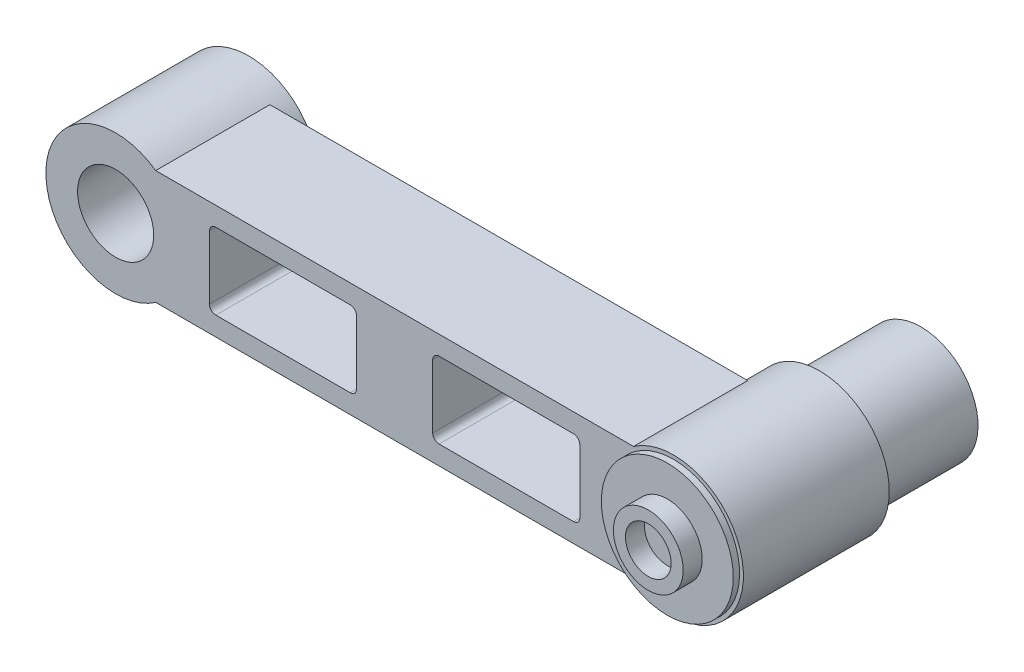
from build123d import *

# Parameters (mm, degrees)
BOSS_EXTRUDE5_DEPTH   = 90
SKETCH11_3_R          = 55
BOSS_EXTRUDE6_DEPTH   = 115
SKETCH11_4_R          = 55
BOSS_EXTRUDE7_DEPTH   = 105
BOSS_EXTRUDE8_DEPTH   = 15
SKETCH17_R            = 45
BOSS_EXTRUDE9_DEPTH   = 80
SKETCH18_R            = 52
BOSS_EXTRUDE10_DEPTH  = 5
SKETCH19_R            = 27.5
SKETCH19_R_2          = 18
BOSS_EXTRUDE12_DEPTH  = 15
BODY_MOVE_COPY2_ANGLE = 180
SKETCH28_R            = 52
CUT_EXTRUDE2_DEPTH    = 60
CUT_EXTRUDE3_DEPTH    = 80
SKETCH31_R            = 30
CUT_EXTRUDE6_DEPTH    = 196
BODY_MOVE_COPY3_ANGLE = 180
BODY_MOVE_COPY4_ANGLE = 90
BODY_MOVE_COPY6_ANGLE = 180
BODY_MOVE_COPY8_ANGLE = 90
BODY_MOVE_COPY9_ANGLE = 90
SKETCH36_R            = 24.5
CUT_EXTRUDE7_DEPTH    = 60


with BuildPart() as part:
    # Sketch11 → Boss-Extrude5 (new body)
    with BuildSketch(Plane.XY):
        with BuildLine():
            Line((-45, 408.377223398), (-45, 31.622776602))
            ThreePointArc((-45, 31.622776602), (0, -55), (45, 31.622776602))
            Line((45, 31.622776602), (45, 408.377223398))
            ThreePointArc((45, 408.377223398), (0, 495), (-45, 408.377223398))
        make_face()
    extrude(amount=BOSS_EXTRUDE5_DEPTH)

    # Sketch11_3 → Boss-Extrude6 (add)
    with BuildSketch(Plane.XY):
        with Locations((0, 440)):
            Circle(SKETCH11_3_R)
    extrude(amount=BOSS_EXTRUDE6_DEPTH)

    # Sketch11_4 → Boss-Extrude7 (add)
    with BuildSketch(Plane.XY):
        Circle(SKETCH11_4_R)
    extrude(amount=BOSS_EXTRUDE7_DEPTH)

    # Sketch13 → Boss-Extrude8 (add)
    with BuildSketch(Plane.XY.offset(90)):
        with BuildLine():
            Line((7.638888889, 82), (7.638888889, 54.46693838))
            Line((7.638888889, 54.46693838), (-7.638888889, 54.46693838))
            Line((-7.638888889, 54.46693838), (-7.638888889, 82))
            ThreePointArc((-7.638888889, 82), (0, 89.638888889), (7.638888889, 82))
        make_face()
    extrude(amount=BOSS_EXTRUDE8_DEPTH)

    # Sketch17 → Boss-Extrude9 (add)
    with BuildSketch(Plane.XY.offset(115)):
        with Locations((0, 440)):
            Circle(SKETCH17_R)
    extrude(amount=BOSS_EXTRUDE9_DEPTH)

    # Sketch18 → Boss-Extrude10 (add)
    with BuildSketch(Plane(origin=(0, 0, 0), x_dir=(-1, 0, 0), z_dir=(0, 0, -1))):
        with Locations((0, 440)):
            Circle(SKETCH18_R)
    extrude(amount=BOSS_EXTRUDE10_DEPTH)

    # Sketch19 → Boss-Extrude12 (add)
    with BuildSketch(Plane(origin=(0, 0, -5), x_dir=(-1, 0, 0), z_dir=(0, 0, -1))):
        with Locations((0, 440)):
            Circle(SKETCH19_R)
        with Locations((0, 440)):
            Circle(SKETCH19_R_2, mode=Mode.SUBTRACT)
    extrude(amount=BOSS_EXTRUDE12_DEPTH)


with BuildPart() as part_1:
    # Body-Move_Copy2: moved
    add(part.part.rotate(Axis((0, 0, 0), (0, 1, 0)), BODY_MOVE_COPY2_ANGLE))

    # Sketch28 → Cut-Extrude2 (cut)
    with BuildSketch(Plane(origin=(0, 0, -105), x_dir=(-1, 0, 0), z_dir=(0, 0, -1))):
        Circle(SKETCH28_R)
    extrude(amount=-CUT_EXTRUDE2_DEPTH, mode=Mode.SUBTRACT)

    # Sketch29 → Cut-Extrude3 (cut)
    with BuildSketch(Plane.XY):
        with BuildLine():
            ThreePointArc((-30, 361), (-28.535533906, 364.535533906), (-25, 366))
            Line((-25, 366), (25, 366))
            ThreePointArc((25, 366), (28.535533906, 364.535533906), (30, 361))
            Line((30, 361), (30, 255))
            ThreePointArc((30, 255), (28.535533906, 251.464466094), (25, 250))
            Line((25, 250), (-25, 250))
            ThreePointArc((-25, 250), (-28.535533906, 251.464466094), (-30, 255))
            Line((-30, 255), (-30, 361))
        make_face()
        with BuildLine():
            ThreePointArc((-30, 185), (-28.535533906, 188.535533906), (-25, 190))
            Line((-25, 190), (25, 190))
            ThreePointArc((25, 190), (28.535533906, 188.535533906), (30, 185))
            Line((30, 185), (30, 79))
            ThreePointArc((30, 79), (28.535533906, 75.464466094), (25, 74))
            Line((25, 74), (-25, 74))
            ThreePointArc((-25, 74), (-28.535533906, 75.464466094), (-30, 79))
            Line((-30, 79), (-30, 185))
        make_face()
    extrude(amount=-CUT_EXTRUDE3_DEPTH, mode=Mode.SUBTRACT)

    # Sketch31 → Cut-Extrude6 (cut, through all)
    with BuildSketch(Plane.XY):
        Circle(SKETCH31_R)
    extrude(amount=-CUT_EXTRUDE6_DEPTH, mode=Mode.SUBTRACT)


with BuildPart() as part_2:
    # Body-Move_Copy3: moved
    add(part_1.part.moved(Location((0, 0, 0))).rotate(Axis((0, 0, -87.5), (0, 1, 0)), BODY_MOVE_COPY3_ANGLE))


with BuildPart() as part_3:
    # Body-Move_Copy4: moved
    add(part_2.part.rotate(Axis((0, 225, 0), (0, 0, -1)), BODY_MOVE_COPY4_ANGLE))


with BuildPart() as part_4:
    # Body-Move_Copy6: moved
    add(part_3.part.rotate(Axis((225, 0, -17.5), (0, 1, 0)), BODY_MOVE_COPY6_ANGLE))


with BuildPart() as part_5:
    # Body-Move_Copy7: moved
    add(part_4.part.moved(Location((-675, -225, -35))))


with BuildPart() as part_6:
    # Body-Move_Copy8: moved
    add(part_5.part.rotate(Axis((-225, 0, 0), (0, 0, -1)), BODY_MOVE_COPY8_ANGLE))


with BuildPart() as part_7:
    # Body-Move_Copy9: moved
    add(part_6.part.rotate(Axis((-225, 0, 0), (0, 0, -1)), BODY_MOVE_COPY9_ANGLE))


with BuildPart() as part_8:
    # Body-Move_Copy10: moved
    add(part_7.part.moved(Location((450, 1e-09, 0))))


with BuildPart() as part_9:
    # Body-Move_Copy14: moved
    add(part_8.part.moved(Location((0, 0, 62.63))))

    # Sketch36 → Cut-Extrude7 (cut)
    with BuildSketch(Plane(origin=(0, 0, -27.37), x_dir=(-1, 0, 0), z_dir=(0, 0, -1))):
        with Locations((-440, 2e-09)):
            Circle(SKETCH36_R)
    extrude(amount=-CUT_EXTRUDE7_DEPTH, mode=Mode.SUBTRACT)


solid = part_9.part
